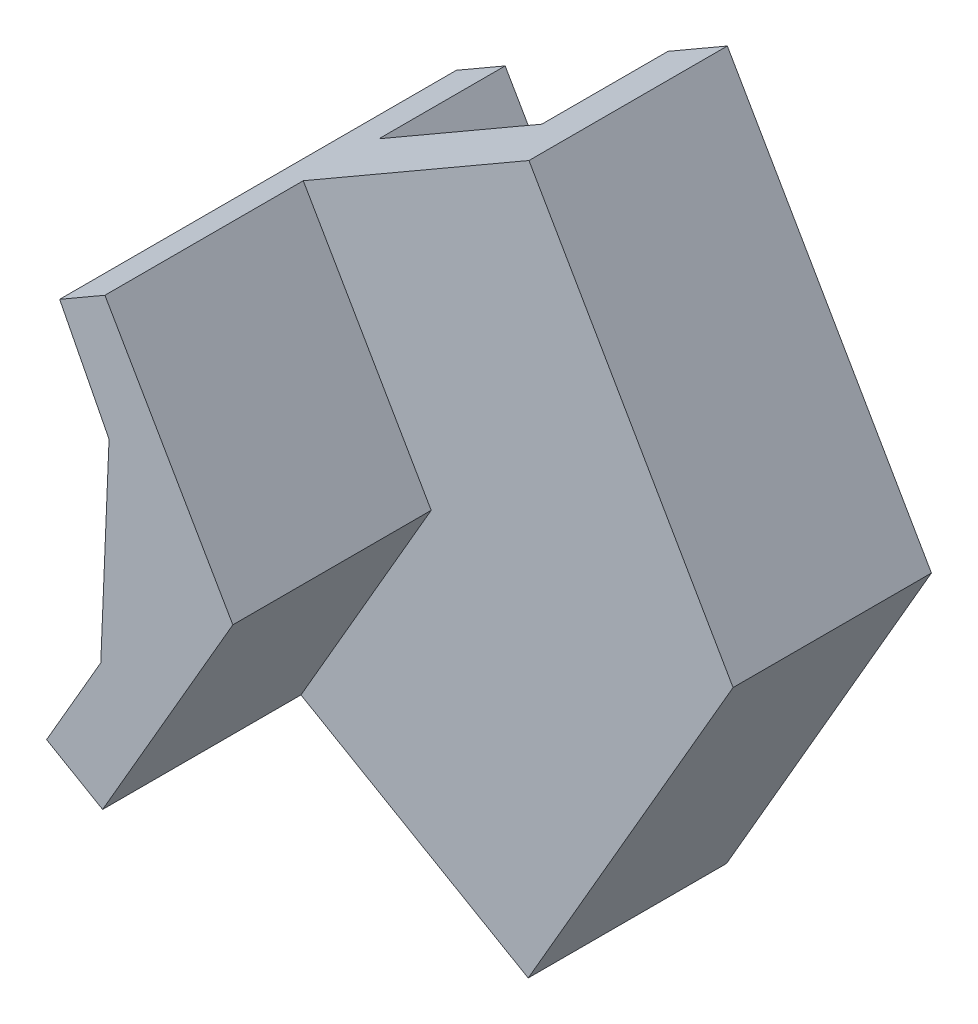
from build123d import *

# Parameters (mm, degrees)
SALIENTE_EXTRUIR1_DEPTH = 2
SALIENTE_EXTRUIR2_DEPTH = 3.5
SALIENTE_EXTRUIR3_DEPTH = 5.5


with BuildPart() as part:
    # Croquis1 → Saliente-Extruir1 (new body)
    with BuildSketch(Plane.XY):
        Polygon((94.631182175, -5.210576854), (102.486249967, -9.756789114), (108.167092376, 0.058723162), (102.507485031, 9.885444115), (94.993770531, 5.545656204), (96.36344276, 2.872304936), (96.133929876, -2.614088967), align=None)
    extrude(amount=SALIENTE_EXTRUIR1_DEPTH)

    # Croquis2 → Saliente-Extruir2 (add)
    with BuildSketch(Plane(origin=(0, 0, 0), x_dir=(-1, 0, 0), z_dir=(0, 0, -1))):
        Polygon((-100.000000028, -1.2e-08), (-96.341228634, -6.200286222), (-94.631182175, -5.210576854), (-96.133929876, -2.614088967), (-96.36344276, 2.872304936), (-94.993770531, 5.545656204), (-96.346967159, 6.327238518), align=None)
        Polygon((-102.486249967, -9.756789114), (-100.841807638, -8.805048903), (-105.980454031, 0.073642516), (-100.862200724, 8.935157151), (-102.507485031, 9.885444115), (-108.167092376, 0.058723162), align=None)
    extrude(amount=SALIENTE_EXTRUIR2_DEPTH)

    # Croquis3 → Saliente-Extruir3 (add)
    with BuildSketch(Plane.XY.offset(2)):
        Polygon((94.631182175, -5.210576854), (96.133929876, -2.614088967), (96.36344276, 2.872304936), (94.993770531, 5.545656204), (96.248686318, 6.270473252), (99.795829711, 0.129107984), (96.184962548, -6.109845399), align=None)
    extrude(amount=SALIENTE_EXTRUIR3_DEPTH)


solid = part.part
